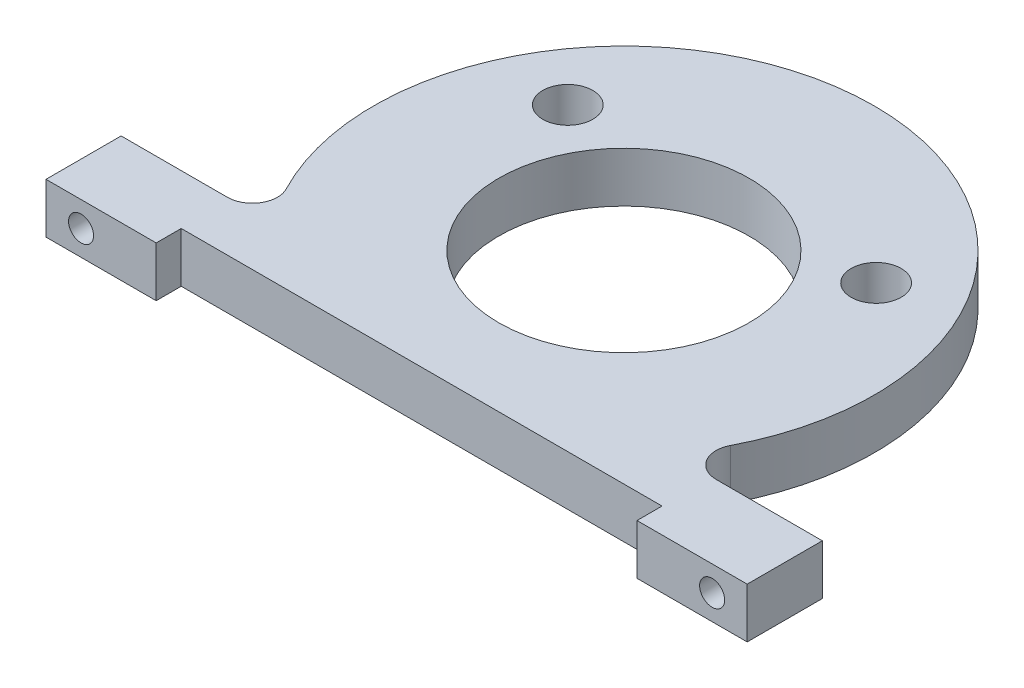
from build123d import *

# Parameters (mm, degrees)
SKETCH1_R           = 25.000012525
SKETCH1_R_2         = 5
BOSS_EXTRUDE1_DEPTH = 10
SKETCH3_R           = 2.5
CUT_EXTRUDE1_DEPTH  = 16
SKETCH4_R           = 2.5
CUT_EXTRUDE2_DEPTH  = 16
FILLET1_R           = 5
FILLET2_R           = 5


with BuildPart() as part:
    # Sketch1 → Boss-Extrude1 (new body)
    with BuildSketch(Plane(origin=(0, 0, 0), x_dir=(1, 0, 0), z_dir=(0, 1, 0))):
        with BuildLine():
            Line((-70, -30.387602841), (-39.706341981, -30.387602841))
            ThreePointArc((-39.706341981, -30.387602841), (0, 50), (39.706341981, -30.387602841))
            Line((39.706341981, -30.387602841), (70, -30.387602841))
            Line((70, -30.387602841), (70, -45.387602841))
            Line((70, -45.387602841), (48, -45.387602841))
            Line((48, -45.387602841), (48, -40.387602841))
            Line((48, -40.387602841), (-48, -40.387602841))
            Line((-48, -40.387602841), (-48, -45.387602841))
            Line((-48, -45.387602841), (-70, -45.387602841))
            Line((-70, -45.387602841), (-70, -30.387602841))
        make_face()
        Circle(SKETCH1_R, mode=Mode.SUBTRACT)
        with Locations((30.781735211, 19.572623378)):
            Circle(SKETCH1_R_2, mode=Mode.SUBTRACT)
        with Locations((-30.781735211, 19.572623378)):
            Circle(SKETCH1_R_2, mode=Mode.SUBTRACT)
    extrude(amount=BOSS_EXTRUDE1_DEPTH)

    # Sketch3 → Cut-Extrude1 (cut, through all)
    with BuildSketch(Plane(origin=(0, 0, 30.387602841), x_dir=(-1, 0, 0), z_dir=(0, 0, -1))):
        with Locations((-63, 5)):
            Circle(SKETCH3_R)
    extrude(amount=-CUT_EXTRUDE1_DEPTH, mode=Mode.SUBTRACT)

    # Sketch4 → Cut-Extrude2 (cut, through all)
    with BuildSketch(Plane(origin=(0, 0, 30.387602841), x_dir=(-1, 0, 0), z_dir=(0, 0, -1))):
        with Locations((63, 5)):
            Circle(SKETCH4_R)
    extrude(amount=-CUT_EXTRUDE2_DEPTH, mode=Mode.SUBTRACT)

    # Fillet1
    fillet1_edges = [part.edges().sort_by_distance(p)[0] for p in [
        (39.706341981, 5, 30.387602841),
    ]]
    fillet(fillet1_edges, radius=FILLET1_R)

    # Fillet2
    fillet2_edges = [part.edges().sort_by_distance(p)[0] for p in [
        (-39.706341981, 5, 30.387602841),
    ]]
    fillet(fillet2_edges, radius=FILLET2_R)


solid = part.part
